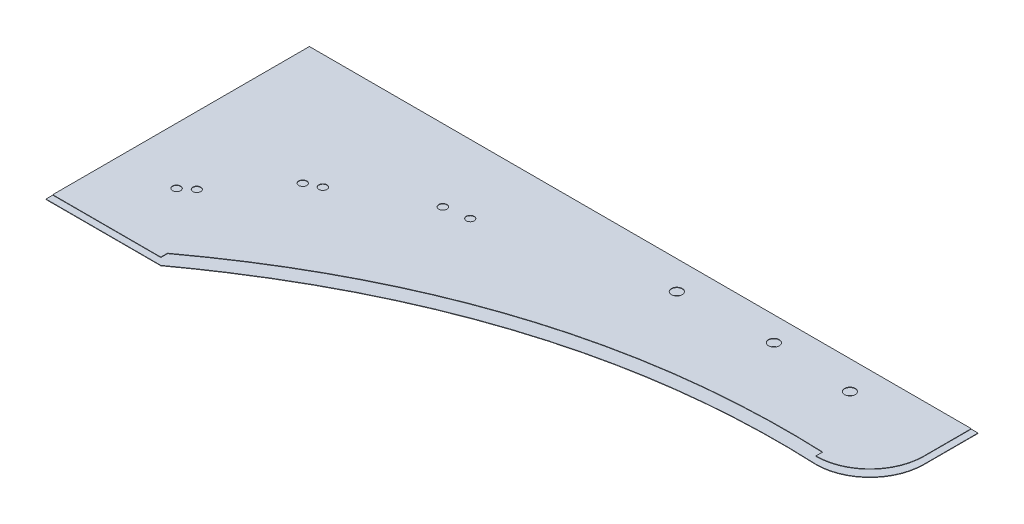
from build123d import *

# Parameters (mm, degrees)
DODANIE_WYCI_GNI_CIE1_DEPTH = 0.3
DODANIE_WYCI_GNI_CIE2_DEPTH = 0.3
SZKIC3_R                    = 4
SZKIC3_R_2                  = 2.944641831
SZKIC3_R_3                  = 3.020576513
SZKIC3_R_4                  = 3.012177803
SZKIC3_R_5                  = 2.969694601
SZKIC3_R_6                  = 2.926354466
SZKIC3_R_7                  = 3.022325106
WYTNIJ_WYCI_GNI_CIE1_DEPTH  = 20


with BuildPart() as part:
    # Szkic1 → Dodanie-wyciągnięcie1 (new body)
    with BuildSketch(Plane(origin=(0, 705, 0), x_dir=(1, 0, 0), z_dir=(0, 1, 0))):
        with BuildLine():
            Line((-66.202987025, -312.681641948), (-66.202987023, -317.681641948))
            ThreePointArc((-66.202987023, -317.681641948), (-37.918715775, -305.965913195), (-26.202987023, -277.681641948))
            Line((-26.202987023, -277.681641948), (-26.202987023, -242.681641948))
            Line((-26.202987023, -242.681641948), (-516.202987023, -242.681641948))
            Line((-516.202987023, -242.681641948), (-516.202987023, -432.681641948))
            Line((-516.202987023, -432.681641948), (-436.202987023, -432.681641948))
            Line((-436.202987023, -432.681641948), (-436.202986934, -427.681641882))
            add(Edge.make_bspline(
                [(-436.202986934, -427.681641882), (-268.546265032, -303.965113503), (-66.202987025, -312.681641948)],
                knots=[0, 0, 0, 1, 1, 1], degree=2))
        make_face()
    extrude(amount=DODANIE_WYCI_GNI_CIE1_DEPTH)


with BuildPart() as body_2:
    # Szkic2 → Dodanie-wyciągnięcie2 (new body)
    with BuildSketch(Plane.XZ.offset(-700)):
        with BuildLine():
            Line((-521.202987023, 432.681641948), (-521.202987023, 237.681641948))
            Line((-521.202987023, 237.681641948), (-26.202987023, 237.681641948))
            Line((-26.202987023, 237.681641948), (-26.202987023, 277.681641948))
            ThreePointArc((-26.202987023, 277.681641948), (-37.918715775, 305.965913195), (-66.202987023, 317.681641948))
            add(Edge.make_bspline(
                [(-66.202987023, 317.681641948), (-265.691193711, 308.349917645), (-436.202986931, 432.681641881)],
                knots=[0, 0, 0, 1, 1, 1], degree=2))
            Line((-436.202986931, 432.681641881), (-521.202987023, 432.681641948))
        make_face()
    extrude(amount=DODANIE_WYCI_GNI_CIE2_DEPTH)


with BuildPart() as wytnij_wyci_gni_cie1_tool:
    # Szkic3 → Wytnij-wyciągnięcie1 (new body)
    with BuildSketch(Plane.XZ.offset(-699.7)):
        with Locations(Location((-94.909521544, 263.802212936, 0), (0, 0, 270))):
            Circle(SZKIC3_R)
        with Locations(Location((-154.344703344, 260.643821632, 0), (0, 0, 270))):
            Circle(SZKIC3_R)
        with Locations(Location((-223.024834581, 263.802212936, 0), (0, 0, 270))):
            Circle(SZKIC3_R)
        with Locations(Location((-346.372819064, 293.429327819, 0), (0, 0, 270))):
            Circle(SZKIC3_R_2)
        with Locations(Location((-364.017672886, 296.048587357, 0), (0, 0, 270))):
            Circle(SZKIC3_R_3)
        with Locations(Location((-421.082774625, 327.809793479, 0), (0, 0, 270))):
            Circle(SZKIC3_R_4)
        with Locations(Location((-431.013382426, 332.771307187, 0), (0, 0, 270))):
            Circle(SZKIC3_R_5)
        with Locations(Location((-466.31780115, 375.923654109, 0), (0, 0, 270))):
            Circle(SZKIC3_R_6)
        with Locations(Location((-474.449169572, 382.793687092, 0), (0, 0, 270))):
            Circle(SZKIC3_R_7)
    extrude(amount=-WYTNIJ_WYCI_GNI_CIE1_DEPTH)


with BuildPart() as part_1:
    add(part.part)

    # Wytnij-wyciągnięcie1: cut by wytnij_wyci_gni_cie1_tool
    add(wytnij_wyci_gni_cie1_tool.part, mode=Mode.SUBTRACT)


with BuildPart() as body_2_1:
    add(body_2.part)

    # Wytnij-wyciągnięcie1: cut by wytnij_wyci_gni_cie1_tool
    add(wytnij_wyci_gni_cie1_tool.part, mode=Mode.SUBTRACT)


solid = Compound([part_1.part, body_2_1.part])
